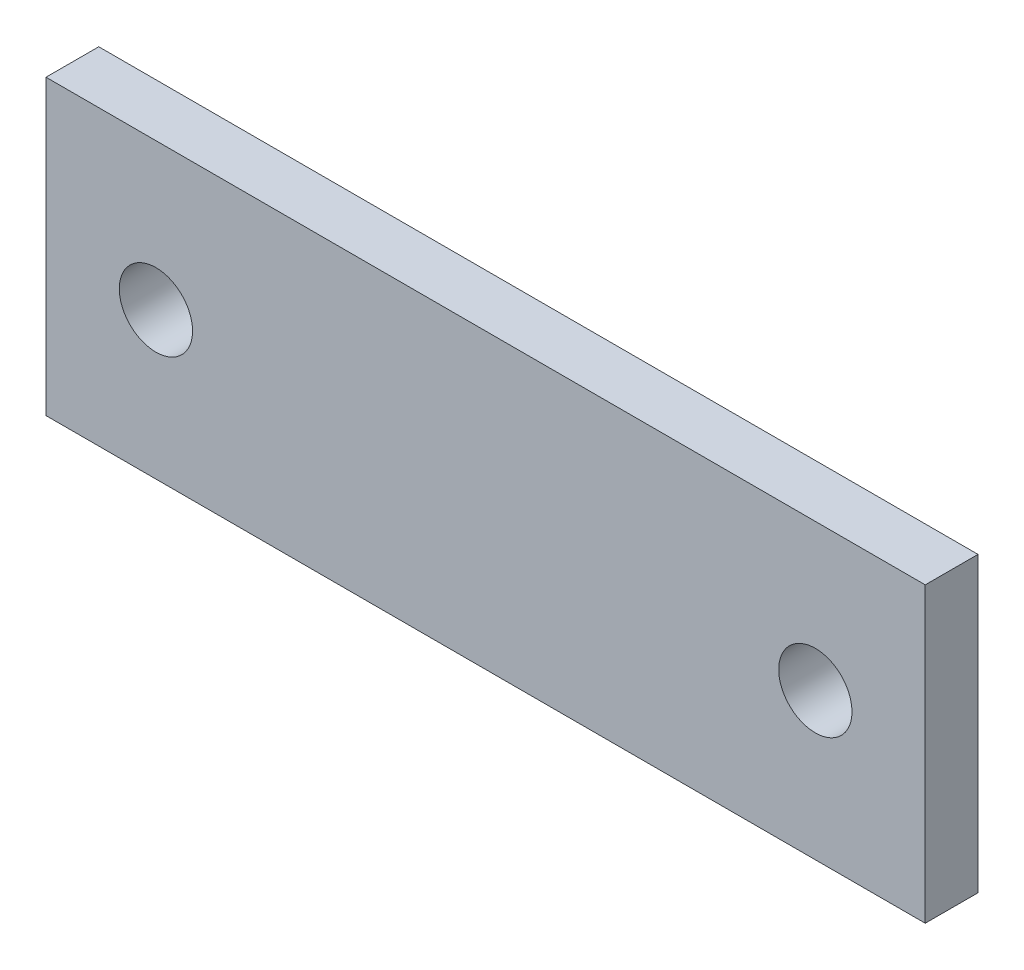
from build123d import *

# Parameters (mm, degrees)
SKETCH3_W                = 76.2
SKETCH3_H                = 25.4
SKETCH3_R                = 3.175
BOSS_EXTRUDE1_DEPTH      = 2.286
BOSS_EXTRUDE1_DEPTH_BACK = 2.286


with BuildPart() as part:
    # Sketch3 → Boss-Extrude1 (new body, two sides)
    with BuildSketch(Plane.XY) as boss_extrude1_sk:
        Rectangle(SKETCH3_W, SKETCH3_H)
        with Locations((-28.575, 0)):
            Circle(SKETCH3_R, mode=Mode.SUBTRACT)
        with Locations((28.575, 0)):
            Circle(SKETCH3_R, mode=Mode.SUBTRACT)
    extrude(amount=BOSS_EXTRUDE1_DEPTH)
    extrude(boss_extrude1_sk.sketch, amount=-BOSS_EXTRUDE1_DEPTH_BACK)


solid = part.part
